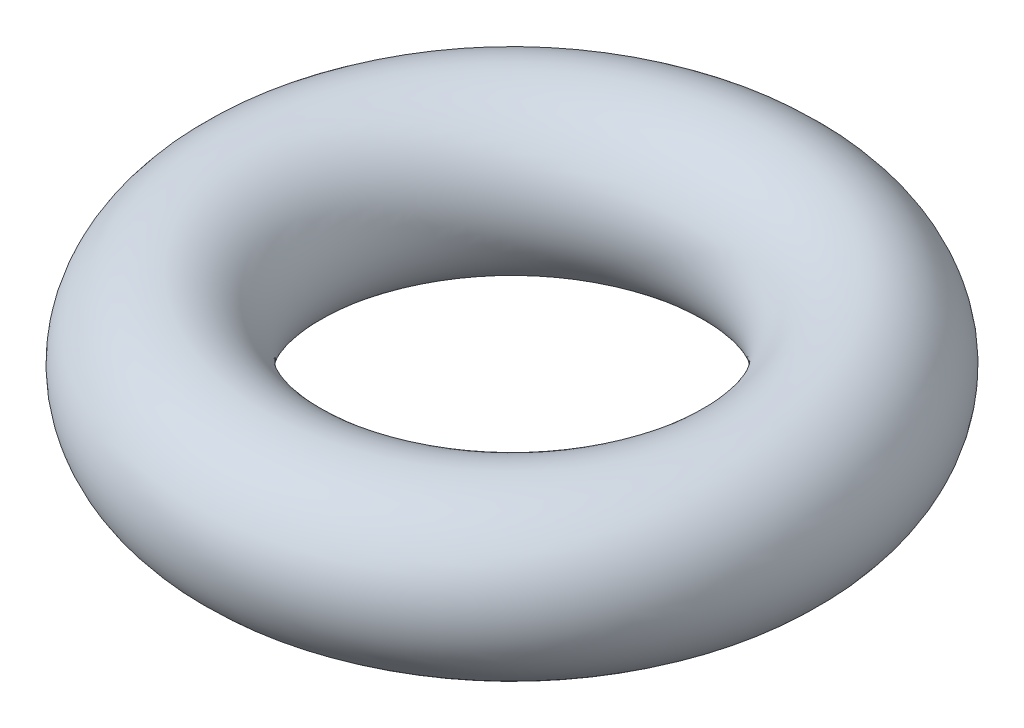
from build123d import *

# Parameters (mm, degrees)
SKETCH2_R = 0.889


with BuildPart() as part:
    # Sketch2 → Revolve1 (revolve)
    with BuildSketch(Plane.XY):
        with Locations((-2.7305, 0)):
            Circle(SKETCH2_R)
    revolve(axis=Axis((0, 0, 0), (0, 1, 0)))


solid = part.part
